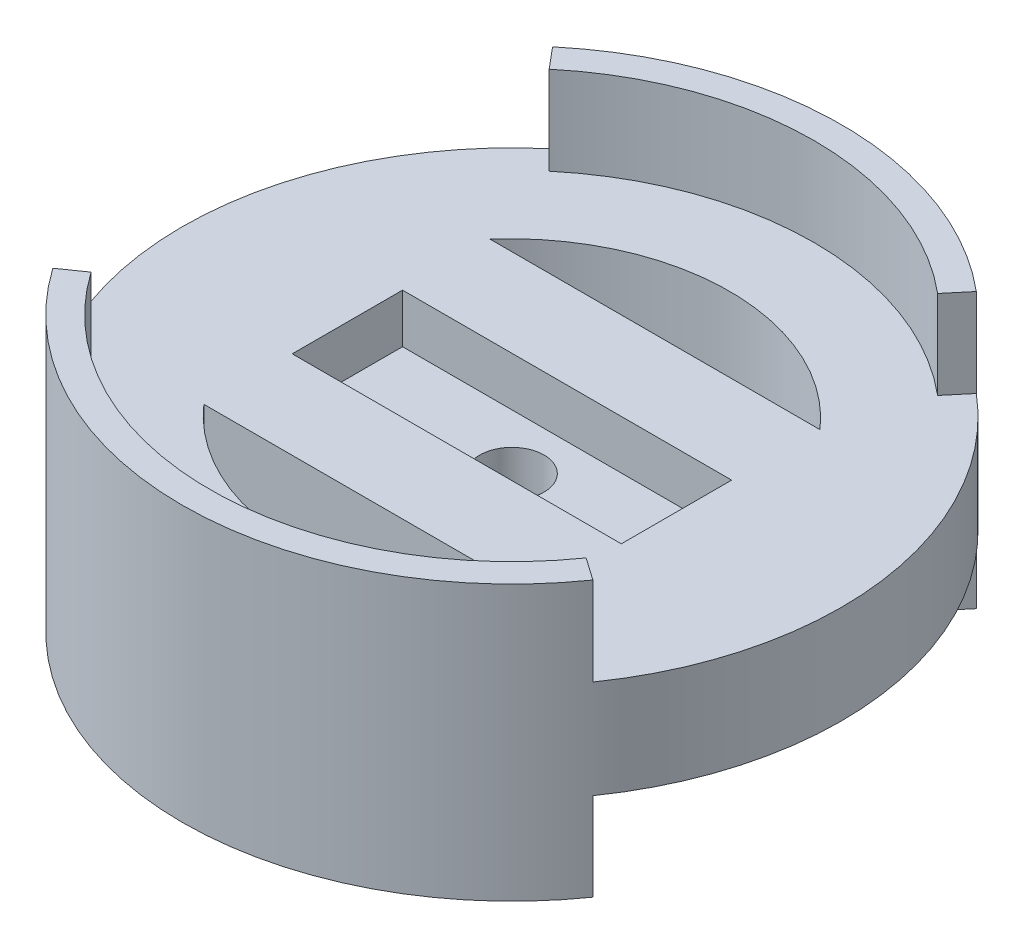
from build123d import *

# Parameters (mm, degrees)
SKETCH1_R           = 38.1
SKETCH1_W           = 38.0365
SKETCH1_H           = 12.7508
BOSS_EXTRUDE1_DEPTH = 5.6642
BOSS_EXTRUDE2_START = -5.715
SKETCH1_3_R         = 38.1
SKETCH1_3_R_2       = 3.71475
BOSS_EXTRUDE2_DEPTH = 5.715
BOSS_EXTRUDE3_DEPTH = 15.875
CUT_EXTRUDE2_DEPTH  = 59.02721


with BuildPart() as part:
    # Sketch1 → Boss-Extrude1 (new body)
    with BuildSketch(Plane(origin=(0, 0, 0), x_dir=(1, 0, 0), z_dir=(0, 1, 0))):
        Circle(SKETCH1_R)
        Rectangle(SKETCH1_W, SKETCH1_H, mode=Mode.SUBTRACT)
    extrude(amount=BOSS_EXTRUDE1_DEPTH)

    # Sketch1_3 → Boss-Extrude2 (add)
    with BuildSketch(Plane(origin=(0, 0, 0), x_dir=(1, 0, 0), z_dir=(0, 1, 0)).offset(BOSS_EXTRUDE2_START)):
        Circle(SKETCH1_3_R)
        Circle(SKETCH1_3_R_2, mode=Mode.SUBTRACT)
    extrude(amount=BOSS_EXTRUDE2_DEPTH)

    # Sketch2 → Boss-Extrude3 (add, symmetric)
    with BuildSketch(Plane(origin=(0, 0, 0), x_dir=(1, 0, 0), z_dir=(0, 1, 0))):
        with BuildLine():
            ThreePointArc((24.490208, 29.186293), (0, 38.1), (-24.490208, 29.186293))
            Line((-24.490208, 29.186293), (-22.449357, 26.754102))
            ThreePointArc((-22.449357, 26.754102), (0, 34.925), (22.449357, 26.754102))
            Line((22.449357, 26.754102), (24.490208, 29.186293))
        make_face()
        with BuildLine():
            ThreePointArc((28.608885, -20.032157), (0, -34.925), (-28.608885, -20.032157))
            Line((-28.608885, -20.032157), (-31.209693, -21.853262))
            ThreePointArc((-31.209693, -21.853262), (0, -38.1), (31.209693, -21.853262))
            Line((31.209693, -21.853262), (28.608885, -20.032157))
        make_face()
    extrude(amount=BOSS_EXTRUDE3_DEPTH, both=True)

    # Sketch3 → Cut-Extrude2 (cut, through all)
    with BuildSketch(Plane(origin=(0, 5.6642, 0), x_dir=(1, 0, 0), z_dir=(0, 1, 0))):
        with BuildLine():
            Line((-19.0754, 16.5354), (19.0754, 16.5354))
            ThreePointArc((19.0754, 16.5354), (0, 25.163724), (-19.0754, 16.5354))
        make_face()
        with BuildLine():
            Line((-19.0754, -16.5354), (19.0754, -16.5354))
            ThreePointArc((19.0754, -16.5354), (0, -25.163724), (-19.0754, -16.5354))
        make_face()
    extrude(amount=-CUT_EXTRUDE2_DEPTH, mode=Mode.SUBTRACT)


solid = part.part
